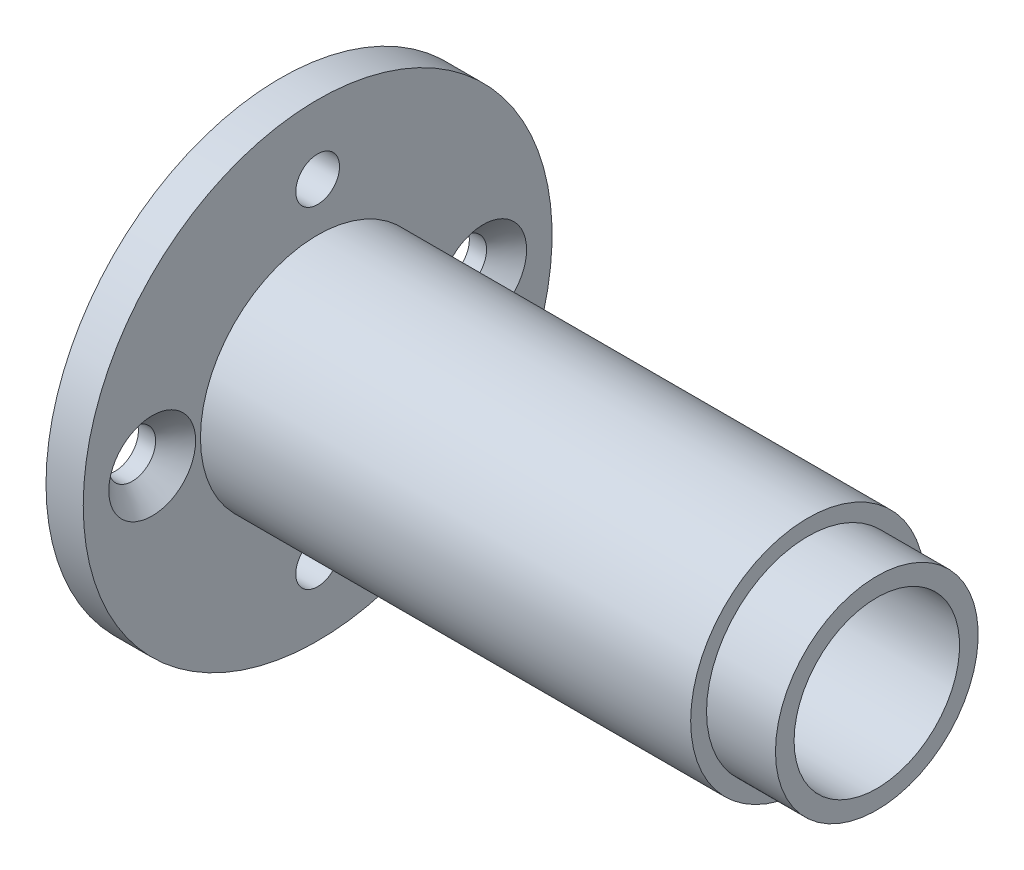
from build123d import *

# Parameters (mm, degrees)
CUT_EXTRUDE1_REACH                                  = 4.7
SKETCH4_R                                           = 1.5875
CSK_FOR_M3_COUNTERSUNK_FLAT_HEAD_SCREW1_D           = 3.4
CSK_FOR_M3_COUNTERSUNK_FLAT_HEAD_SCREW1_DEPTH       = 10
CSK_FOR_M3_COUNTERSUNK_FLAT_HEAD_SCREW1_CSINK_D     = 6.3
CSK_FOR_M3_COUNTERSUNK_FLAT_HEAD_SCREW1_CSINK_ANGLE = 90
CSK_FOR_M3_COUNTERSUNK_FLAT_HEAD_SCREW1_TIP         = 1.021463052
SKETCH14_R                                          = 0.8
CUT_EXTRUDE3_DEPTH                                  = 10


with BuildPart() as part:
    # Sketch3 → Revolve19 (revolve)
    with BuildSketch(Plane.XY):
        Polygon((299.808388758, -140.073704322), (264.258388758, -140.073704322), (264.258388758, -131.573704322), (261.558388758, -131.573704322), (261.558388758, -143.823704322), (261.558388758, -145.323704322), (262.558388758, -145.323704322), (264.258388758, -145.323704322), (264.258388758, -142.573704322), (304.808388758, -142.573704322), (304.808388758, -141.223704322), (299.808388758, -141.223704322), align=None)
    revolve(axis=Axis((227.370475166, -148.573704322, 0), (1, 0, 0)))

    # Sketch4 → Cut-Extrude1 (cut, up to next)
    with BuildSketch(Plane(origin=(264.258388758, 0, 0), x_dir=(0, 0, -1), z_dir=(1, 0, 0)), mode=Mode.PRIVATE) as cut_extrude1_sk1:
        with Locations((0, -136.573704322)):
            Circle(SKETCH4_R)
    cut_extrude1_tool1 = extrude(cut_extrude1_sk1.sketch, amount=-CUT_EXTRUDE1_REACH, mode=Mode.PRIVATE) & part.part
    add(cut_extrude1_tool1.solids().sort_by_distance((264.258389, -136.573704, 0))[0], mode=Mode.SUBTRACT)
    # Sketch4 → Cut-Extrude1 (cut, up to next)
    with BuildSketch(Plane(origin=(264.258388758, 0, 0), x_dir=(0, 0, -1), z_dir=(1, 0, 0)), mode=Mode.PRIVATE) as cut_extrude1_sk2:
        with Locations((0, -160.573704322)):
            Circle(SKETCH4_R)
    cut_extrude1_tool2 = extrude(cut_extrude1_sk2.sketch, amount=-CUT_EXTRUDE1_REACH, mode=Mode.PRIVATE) & part.part
    add(cut_extrude1_tool2.solids().sort_by_distance((264.258389, -160.573704, 0))[0], mode=Mode.SUBTRACT)

    # CSK for M3 Countersunk Flat Head Screw1
    with Locations(Plane(origin=(264.258388758, 0, 0), x_dir=(0, 0, -1), z_dir=(1, 0, 0))):
        with Locations((-12, -148.573704322), (12, -148.573704322)):
            CounterSinkHole(CSK_FOR_M3_COUNTERSUNK_FLAT_HEAD_SCREW1_D / 2, CSK_FOR_M3_COUNTERSUNK_FLAT_HEAD_SCREW1_CSINK_D / 2, depth=CSK_FOR_M3_COUNTERSUNK_FLAT_HEAD_SCREW1_DEPTH, counter_sink_angle=CSK_FOR_M3_COUNTERSUNK_FLAT_HEAD_SCREW1_CSINK_ANGLE)
            with Locations((0, 0, -(CSK_FOR_M3_COUNTERSUNK_FLAT_HEAD_SCREW1_DEPTH + CSK_FOR_M3_COUNTERSUNK_FLAT_HEAD_SCREW1_TIP / 2))):  # 118° drill point
                Cone(0, CSK_FOR_M3_COUNTERSUNK_FLAT_HEAD_SCREW1_D / 2, CSK_FOR_M3_COUNTERSUNK_FLAT_HEAD_SCREW1_TIP, mode=Mode.SUBTRACT)

    # Sketch14 → Cut-Extrude3 (cut)
    with BuildSketch(Plane(origin=(264.258388758, 0, 0), x_dir=(0, 0, -1), z_dir=(1, 0, 0))):
        with Locations((-2.899137803, -151.472842125)):
            Circle(SKETCH14_R)
    extrude(amount=-CUT_EXTRUDE3_DEPTH, mode=Mode.SUBTRACT)


solid = part.part
